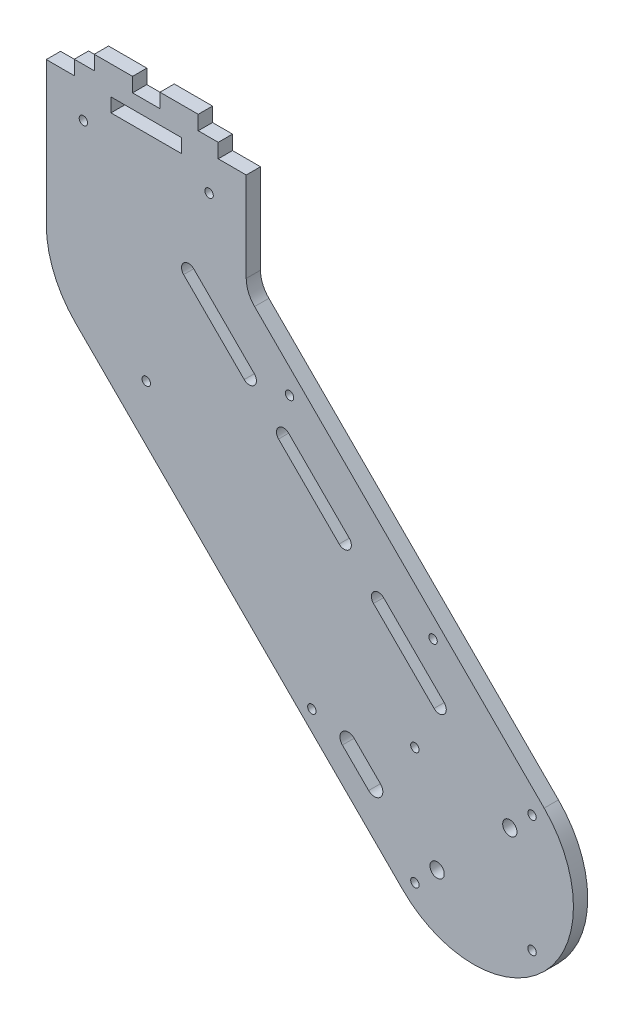
from build123d import *

# Parameters (mm, degrees)
SKETCH1_R           = 1.475
SKETCH1_R_2         = 2.5
SKETCH1_W           = 24.7
SKETCH1_H           = 4.85
BOSS_EXTRUDE1_DEPTH = 5


with BuildPart() as part:
    # Sketch1 → Boss-Extrude1 (new body)
    with BuildSketch(Plane.XY):
        with BuildLine():
            Line((-139.300035894, 89.802561211), (-24.748737342, -24.748737342))
            ThreePointArc((-24.748737342, -24.748737342), (24.748737342, -24.748737342), (24.748737342, 24.748737342))
            Line((24.748737342, 24.748737342), (-54.672802234, 104.170276917))
            Line((-54.672802234, 104.170276917), (-76.622366364, 126.119841047))
            ThreePointArc((-76.622366364, 126.119841047), (-78.790093877, 129.364074535), (-79.551298552, 133.190908859))
            Line((-79.551298552, 133.190908859), (-79.551298552, 164.551298552))
            Line((-79.551298552, 164.551298552), (-89.351298552, 164.551298552))
            Line((-89.351298552, 164.551298552), (-89.351298552, 169.551298552))
            Line((-89.351298552, 169.551298552), (-96.351298552, 169.551298552))
            Line((-96.351298552, 169.551298552), (-96.351298552, 174.551298552))
            Line((-96.351298552, 174.551298552), (-109.751298552, 174.551298552))
            Line((-109.751298552, 174.551298552), (-109.751298552, 169.551298552))
            Line((-109.751298552, 169.551298552), (-119.351298552, 169.551298552))
            Line((-119.351298552, 169.551298552), (-119.351298552, 174.551298552))
            Line((-119.351298552, 174.551298552), (-132.751298552, 174.551298552))
            Line((-132.751298552, 174.551298552), (-132.751298552, 169.551298552))
            Line((-132.751298552, 169.551298552), (-139.751298552, 169.551298552))
            Line((-139.751298552, 169.551298552), (-139.751298552, 164.551298552))
            Line((-139.751298552, 164.551298552), (-149.551298552, 164.551298552))
            Line((-149.551298552, 164.551298552), (-149.551298552, 114.551298552))
            ThreePointArc((-149.551298552, 114.551298552), (-146.88708219, 101.157378419), (-139.300035894, 89.802561211))
        make_face()
        with Locations((-20.506096654, -20.506096654)):
            Circle(SKETCH1_R, mode=Mode.SUBTRACT)
        with Locations((-12.727922061, -12.727922061)):
            Circle(SKETCH1_R_2, mode=Mode.SUBTRACT)
        with Locations((-56.568542495, 14.142135624)):
            Circle(SKETCH1_R, mode=Mode.SUBTRACT)
        with BuildLine():
            ThreePointArc((-45.891723759, 8.555498392), (-45.891723759, 12.670859859), (-41.776362292, 12.670859859))
            Line((-41.776362292, 12.670859859), (-32.583974137, 3.478471703))
            ThreePointArc((-32.583974137, 3.478471703), (-32.583974137, -0.636889763), (-36.699335604, -0.636889763))
            Line((-36.699335604, -0.636889763), (-45.891723759, 8.555498392))
        make_face(mode=Mode.SUBTRACT)
        with Locations((20.506096654, -20.506096654)):
            Circle(SKETCH1_R, mode=Mode.SUBTRACT)
        with Locations((12.727922061, 12.727922061)):
            Circle(SKETCH1_R_2, mode=Mode.SUBTRACT)
        with Locations((-20.506096654, 20.506096654)):
            Circle(SKETCH1_R, mode=Mode.SUBTRACT)
        with BuildLine():
            ThreePointArc((-35.001785669, 56.922095886), (-35.001785669, 60.457629791), (-31.466251763, 60.457629791))
            Line((-31.466251763, 60.457629791), (-10.253048327, 39.244426356))
            ThreePointArc((-10.253048327, 39.244426356), (-10.253048327, 35.70889245), (-13.788582233, 35.70889245))
            Line((-13.788582233, 35.70889245), (-35.001785669, 56.922095886))
        make_face(mode=Mode.SUBTRACT)
        with Locations((-14.142135624, 56.568542495)):
            Circle(SKETCH1_R, mode=Mode.SUBTRACT)
        with Locations((20.506096654, 20.506096654)):
            Circle(SKETCH1_R, mode=Mode.SUBTRACT)
        with Locations((-114.551298552, 84.551298552)):
            Circle(SKETCH1_R, mode=Mode.SUBTRACT)
        with BuildLine():
            ThreePointArc((-101.4698231, 123.390133317), (-101.4698231, 126.925667223), (-97.934289194, 126.925667223))
            Line((-97.934289194, 126.925667223), (-76.721085759, 105.712463787))
            ThreePointArc((-76.721085759, 105.712463787), (-76.721085759, 102.176929881), (-80.256619665, 102.176929881))
            Line((-80.256619665, 102.176929881), (-101.4698231, 123.390133317))
        make_face(mode=Mode.SUBTRACT)
        with Locations((-64.396887007, 105.308740477)):
            Circle(SKETCH1_R, mode=Mode.SUBTRACT)
        with Locations((-136.551298552, 152.551298552)):
            Circle(SKETCH1_R, mode=Mode.SUBTRACT)
        with Locations((-114.551298552, 162.126298552)):
            Rectangle(SKETCH1_W, SKETCH1_H, mode=Mode.SUBTRACT)
        with Locations((-92.551298552, 152.551298552)):
            Circle(SKETCH1_R, mode=Mode.SUBTRACT)
        with BuildLine():
            ThreePointArc((-68.235804384, 90.156114601), (-68.235804384, 93.691648507), (-64.700270479, 93.691648507))
            Line((-64.700270479, 93.691648507), (-43.487067043, 72.478445072))
            ThreePointArc((-43.487067043, 72.478445072), (-43.487067043, 68.942911166), (-47.022600949, 68.942911166))
            Line((-47.022600949, 68.942911166), (-68.235804384, 90.156114601))
        make_face(mode=Mode.SUBTRACT)
    extrude(amount=-BOSS_EXTRUDE1_DEPTH)


solid = part.part
